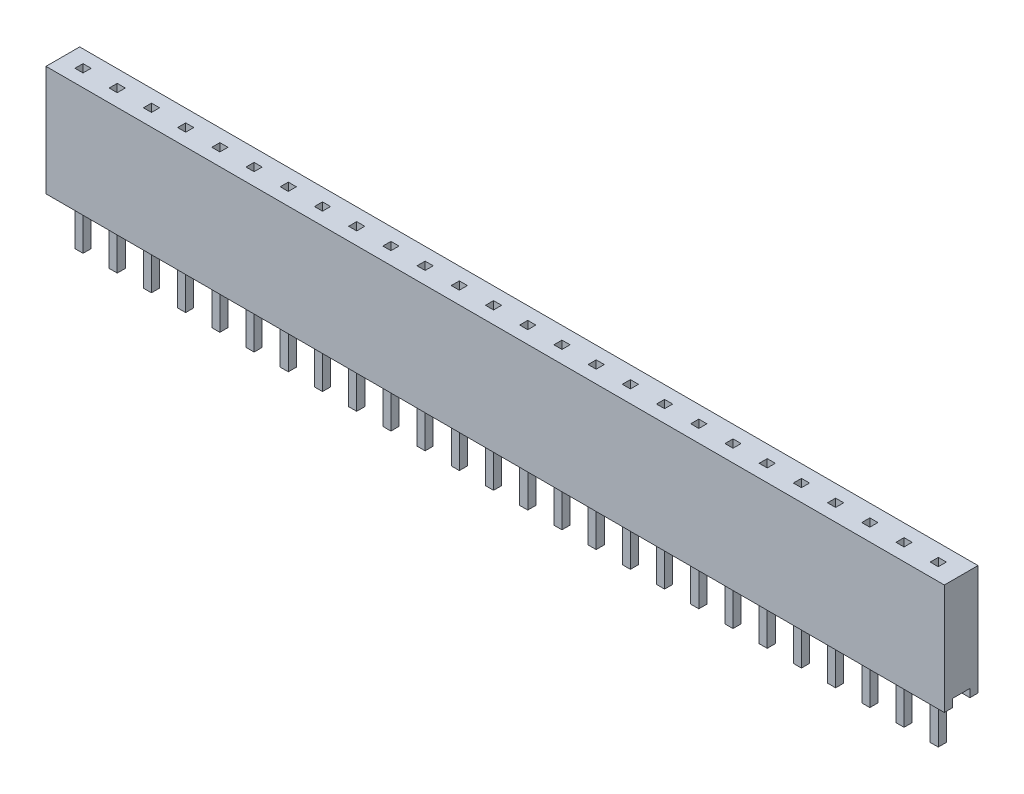
from build123d import *

# Parameters (mm, degrees)
SKETCH1_W                 = 66.7004
SKETCH1_H                 = 2.5
BODY_DEPTH                = 8.2
SKETCH2_W                 = 1.3
SKETCH2_H                 = 0.6
BASE_CUT_DEPTH            = 67.7004
SKETCH3_W                 = 0.6
SKETCH3_H                 = 0.6
PIN_HOLE_DEPTH            = 9.2
LPATTERN1_COUNT           = 26
LPATTERN1_PITCH           = 2.54
SKETCH5_W                 = 0.6
SKETCH5_H                 = 0.6
PCB_STRAIGHT_PIN_DEPTH    = 4
PCB_STRAIGHT_PIN_2_DEPTH  = 4
PCB_STRAIGHT_PIN_3_DEPTH  = 4
PCB_STRAIGHT_PIN_4_DEPTH  = 4
PCB_STRAIGHT_PIN_5_DEPTH  = 4
PCB_STRAIGHT_PIN_6_DEPTH  = 4
PCB_STRAIGHT_PIN_7_DEPTH  = 4
PCB_STRAIGHT_PIN_8_DEPTH  = 4
PCB_STRAIGHT_PIN_9_DEPTH  = 4
PCB_STRAIGHT_PIN_10_DEPTH = 4
PCB_STRAIGHT_PIN_11_DEPTH = 4
PCB_STRAIGHT_PIN_12_DEPTH = 4
PCB_STRAIGHT_PIN_13_DEPTH = 4
PCB_STRAIGHT_PIN_14_DEPTH = 4
PCB_STRAIGHT_PIN_15_DEPTH = 4
PCB_STRAIGHT_PIN_16_DEPTH = 4
PCB_STRAIGHT_PIN_17_DEPTH = 4
PCB_STRAIGHT_PIN_18_DEPTH = 4
PCB_STRAIGHT_PIN_19_DEPTH = 4
PCB_STRAIGHT_PIN_20_DEPTH = 4
PCB_STRAIGHT_PIN_21_DEPTH = 4
PCB_STRAIGHT_PIN_22_DEPTH = 4
PCB_STRAIGHT_PIN_23_DEPTH = 4
PCB_STRAIGHT_PIN_24_DEPTH = 4
PCB_STRAIGHT_PIN_25_DEPTH = 4
PCB_STRAIGHT_PIN_26_DEPTH = 4


with BuildPart() as part:
    # Sketch1 → Body (new body)
    with BuildSketch(Plane(origin=(0, 0, 0), x_dir=(1, 0, 0), z_dir=(0, 1, 0))):
        with Locations((33.3502, 1.25)):
            Rectangle(SKETCH1_W, SKETCH1_H)
    extrude(amount=-BODY_DEPTH)

    # Sketch2 → Base Cut (cut, through all)
    with BuildSketch(Plane(origin=(66.7004, 0, 0), x_dir=(0, 0, -1), z_dir=(1, 0, 0))):
        with Locations((1.25, -7.9)):
            Rectangle(SKETCH2_W, SKETCH2_H)
    extrude(amount=-BASE_CUT_DEPTH, mode=Mode.SUBTRACT)

    # Sketch3 → Pin Hole (cut, through all)
    with BuildSketch(Plane(origin=(0, 0, 0), x_dir=(1, 0, 0), z_dir=(0, 1, 0))):
        with Locations((1.5, 1.25)):
            Rectangle(SKETCH3_W, SKETCH3_H)
    pin_hole = extrude(amount=-PIN_HOLE_DEPTH, mode=Mode.SUBTRACT)

    # LPattern1: Pin Hole ×26
    with Locations(*[(i * LPATTERN1_PITCH, 0, 0) for i in range(1, LPATTERN1_COUNT)]):
        add(pin_hole, mode=Mode.SUBTRACT)


with BuildPart() as body_2:
    # Sketch5 → PCB Straight Pin (new body)
    with BuildSketch(Plane.XZ.offset(7.6)):
        with Locations((1.5, -1.25)):
            Rectangle(SKETCH5_W, SKETCH5_H)
    extrude(amount=PCB_STRAIGHT_PIN_DEPTH)


with BuildPart() as body_3:
    # Sketch5 → PCB Straight Pin 2 (new body)
    with BuildSketch(Plane.XZ.offset(7.6)):
        with Locations((4.04, -1.25)):
            Rectangle(SKETCH5_W, SKETCH5_H)
    extrude(amount=PCB_STRAIGHT_PIN_2_DEPTH)


with BuildPart() as body_4:
    # Sketch5 → PCB Straight Pin 3 (new body)
    with BuildSketch(Plane.XZ.offset(7.6)):
        with Locations((6.58, -1.25)):
            Rectangle(SKETCH5_W, SKETCH5_H)
    extrude(amount=PCB_STRAIGHT_PIN_3_DEPTH)


with BuildPart() as body_5:
    # Sketch5 → PCB Straight Pin 4 (new body)
    with BuildSketch(Plane.XZ.offset(7.6)):
        with Locations((9.12, -1.25)):
            Rectangle(SKETCH5_W, SKETCH5_H)
    extrude(amount=PCB_STRAIGHT_PIN_4_DEPTH)


with BuildPart() as body_6:
    # Sketch5 → PCB Straight Pin 5 (new body)
    with BuildSketch(Plane.XZ.offset(7.6)):
        with Locations((11.66, -1.25)):
            Rectangle(SKETCH5_W, SKETCH5_H)
    extrude(amount=PCB_STRAIGHT_PIN_5_DEPTH)


with BuildPart() as body_7:
    # Sketch5 → PCB Straight Pin 6 (new body)
    with BuildSketch(Plane.XZ.offset(7.6)):
        with Locations((14.2, -1.25)):
            Rectangle(SKETCH5_W, SKETCH5_H)
    extrude(amount=PCB_STRAIGHT_PIN_6_DEPTH)


with BuildPart() as body_8:
    # Sketch5 → PCB Straight Pin 7 (new body)
    with BuildSketch(Plane.XZ.offset(7.6)):
        with Locations((16.74, -1.25)):
            Rectangle(SKETCH5_W, SKETCH5_H)
    extrude(amount=PCB_STRAIGHT_PIN_7_DEPTH)


with BuildPart() as body_9:
    # Sketch5 → PCB Straight Pin 8 (new body)
    with BuildSketch(Plane.XZ.offset(7.6)):
        with Locations((19.28, -1.25)):
            Rectangle(SKETCH5_W, SKETCH5_H)
    extrude(amount=PCB_STRAIGHT_PIN_8_DEPTH)


with BuildPart() as body_10:
    # Sketch5 → PCB Straight Pin 9 (new body)
    with BuildSketch(Plane.XZ.offset(7.6)):
        with Locations((21.82, -1.25)):
            Rectangle(SKETCH5_W, SKETCH5_H)
    extrude(amount=PCB_STRAIGHT_PIN_9_DEPTH)


with BuildPart() as body_11:
    # Sketch5 → PCB Straight Pin 10 (new body)
    with BuildSketch(Plane.XZ.offset(7.6)):
        with Locations((24.36, -1.25)):
            Rectangle(SKETCH5_W, SKETCH5_H)
    extrude(amount=PCB_STRAIGHT_PIN_10_DEPTH)


with BuildPart() as body_12:
    # Sketch5 → PCB Straight Pin 11 (new body)
    with BuildSketch(Plane.XZ.offset(7.6)):
        with Locations((26.9, -1.25)):
            Rectangle(SKETCH5_W, SKETCH5_H)
    extrude(amount=PCB_STRAIGHT_PIN_11_DEPTH)


with BuildPart() as body_13:
    # Sketch5 → PCB Straight Pin 12 (new body)
    with BuildSketch(Plane.XZ.offset(7.6)):
        with Locations((29.44, -1.25)):
            Rectangle(SKETCH5_W, SKETCH5_H)
    extrude(amount=PCB_STRAIGHT_PIN_12_DEPTH)


with BuildPart() as body_14:
    # Sketch5 → PCB Straight Pin 13 (new body)
    with BuildSketch(Plane.XZ.offset(7.6)):
        with Locations((31.98, -1.25)):
            Rectangle(SKETCH5_W, SKETCH5_H)
    extrude(amount=PCB_STRAIGHT_PIN_13_DEPTH)


with BuildPart() as body_15:
    # Sketch5 → PCB Straight Pin 14 (new body)
    with BuildSketch(Plane.XZ.offset(7.6)):
        with Locations((34.52, -1.25)):
            Rectangle(SKETCH5_W, SKETCH5_H)
    extrude(amount=PCB_STRAIGHT_PIN_14_DEPTH)


with BuildPart() as body_16:
    # Sketch5 → PCB Straight Pin 15 (new body)
    with BuildSketch(Plane.XZ.offset(7.6)):
        with Locations((37.06, -1.25)):
            Rectangle(SKETCH5_W, SKETCH5_H)
    extrude(amount=PCB_STRAIGHT_PIN_15_DEPTH)


with BuildPart() as body_17:
    # Sketch5 → PCB Straight Pin 16 (new body)
    with BuildSketch(Plane.XZ.offset(7.6)):
        with Locations((39.6, -1.25)):
            Rectangle(SKETCH5_W, SKETCH5_H)
    extrude(amount=PCB_STRAIGHT_PIN_16_DEPTH)


with BuildPart() as body_18:
    # Sketch5 → PCB Straight Pin 17 (new body)
    with BuildSketch(Plane.XZ.offset(7.6)):
        with Locations((42.14, -1.25)):
            Rectangle(SKETCH5_W, SKETCH5_H)
    extrude(amount=PCB_STRAIGHT_PIN_17_DEPTH)


with BuildPart() as body_19:
    # Sketch5 → PCB Straight Pin 18 (new body)
    with BuildSketch(Plane.XZ.offset(7.6)):
        with Locations((44.68, -1.25)):
            Rectangle(SKETCH5_W, SKETCH5_H)
    extrude(amount=PCB_STRAIGHT_PIN_18_DEPTH)


with BuildPart() as body_20:
    # Sketch5 → PCB Straight Pin 19 (new body)
    with BuildSketch(Plane.XZ.offset(7.6)):
        with Locations((47.22, -1.25)):
            Rectangle(SKETCH5_W, SKETCH5_H)
    extrude(amount=PCB_STRAIGHT_PIN_19_DEPTH)


with BuildPart() as body_21:
    # Sketch5 → PCB Straight Pin 20 (new body)
    with BuildSketch(Plane.XZ.offset(7.6)):
        with Locations((49.76, -1.25)):
            Rectangle(SKETCH5_W, SKETCH5_H)
    extrude(amount=PCB_STRAIGHT_PIN_20_DEPTH)


with BuildPart() as body_22:
    # Sketch5 → PCB Straight Pin 21 (new body)
    with BuildSketch(Plane.XZ.offset(7.6)):
        with Locations((52.3, -1.25)):
            Rectangle(SKETCH5_W, SKETCH5_H)
    extrude(amount=PCB_STRAIGHT_PIN_21_DEPTH)


with BuildPart() as body_23:
    # Sketch5 → PCB Straight Pin 22 (new body)
    with BuildSketch(Plane.XZ.offset(7.6)):
        with Locations((54.84, -1.25)):
            Rectangle(SKETCH5_W, SKETCH5_H)
    extrude(amount=PCB_STRAIGHT_PIN_22_DEPTH)


with BuildPart() as body_24:
    # Sketch5 → PCB Straight Pin 23 (new body)
    with BuildSketch(Plane.XZ.offset(7.6)):
        with Locations((57.38, -1.25)):
            Rectangle(SKETCH5_W, SKETCH5_H)
    extrude(amount=PCB_STRAIGHT_PIN_23_DEPTH)


with BuildPart() as body_25:
    # Sketch5 → PCB Straight Pin 24 (new body)
    with BuildSketch(Plane.XZ.offset(7.6)):
        with Locations((59.92, -1.25)):
            Rectangle(SKETCH5_W, SKETCH5_H)
    extrude(amount=PCB_STRAIGHT_PIN_24_DEPTH)


with BuildPart() as body_26:
    # Sketch5 → PCB Straight Pin 25 (new body)
    with BuildSketch(Plane.XZ.offset(7.6)):
        with Locations((62.46, -1.25)):
            Rectangle(SKETCH5_W, SKETCH5_H)
    extrude(amount=PCB_STRAIGHT_PIN_25_DEPTH)


with BuildPart() as body_27:
    # Sketch5 → PCB Straight Pin 26 (new body)
    with BuildSketch(Plane.XZ.offset(7.6)):
        with Locations((65, -1.25)):
            Rectangle(SKETCH5_W, SKETCH5_H)
    extrude(amount=PCB_STRAIGHT_PIN_26_DEPTH)


solid = Compound([part.part, body_2.part, body_3.part, body_4.part, body_5.part, body_6.part, body_7.part, body_8.part, body_9.part, body_10.part, body_11.part, body_12.part, body_13.part, body_14.part, body_15.part, body_16.part, body_17.part, body_18.part, body_19.part, body_20.part, body_21.part, body_22.part, body_23.part, body_24.part, body_25.part, body_26.part, body_27.part])
